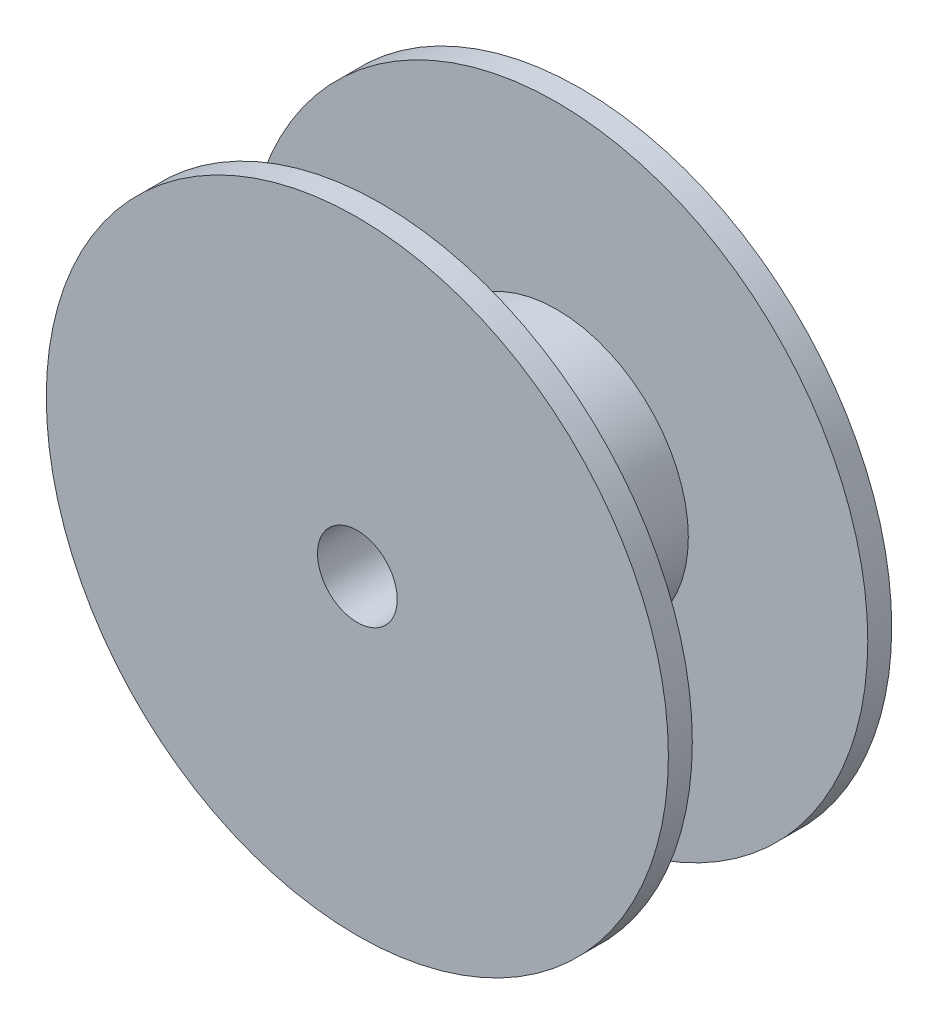
from build123d import *

# Parameters (mm, degrees)
BOSS_EXTRUDE1_DEPTH      = 35.56
BOSS_EXTRUDE1_DEPTH_BACK = 35.56
SKETCH1_R                = 99.06
CUT_EXTRUDE1_DEPTH       = 27.94
CUT_EXTRUDE1_DEPTH_BACK  = 27.94
SKETCH3_OUTSIDE_W        = 257.934
SKETCH3_OUTSIDE_H        = 257.934
SKETCH3_OUTSIDE_R        = 41.91
CUT_EXTRUDE2_DEPTH       = 145.534704483
CUT_EXTRUDE2_DEPTH_BACK  = 145.534704483
SKETCH4_R                = 12.7


with BuildPart() as part:
    # Sketch1 → Boss-Extrude1 (new, two sides: drawn at the far end of the back side and taken through both)
    with BuildSketch(Plane.XY.offset(-BOSS_EXTRUDE1_DEPTH_BACK)):
        Circle(SKETCH1_R)
    extrude(amount=BOSS_EXTRUDE1_DEPTH + BOSS_EXTRUDE1_DEPTH_BACK)

    # Sketch3 outside → Cut-Extrude1 (cut, two sides: drawn at the far end of the back side and taken through both)
    with BuildSketch(Plane.XY.offset(-CUT_EXTRUDE1_DEPTH_BACK)):
        Rectangle(SKETCH3_OUTSIDE_W, SKETCH3_OUTSIDE_H)
        Circle(SKETCH3_OUTSIDE_R, mode=Mode.SUBTRACT)
    extrude(amount=CUT_EXTRUDE1_DEPTH + CUT_EXTRUDE1_DEPTH_BACK, mode=Mode.SUBTRACT)

    # Sketch4 → Cut-Extrude2 (cut, two sides: drawn at the far end of the back side and taken through both)
    with BuildSketch(Plane.XY.offset(-CUT_EXTRUDE2_DEPTH_BACK)):
        Circle(SKETCH4_R)
    extrude(amount=CUT_EXTRUDE2_DEPTH + CUT_EXTRUDE2_DEPTH_BACK, mode=Mode.SUBTRACT)


solid = part.part
